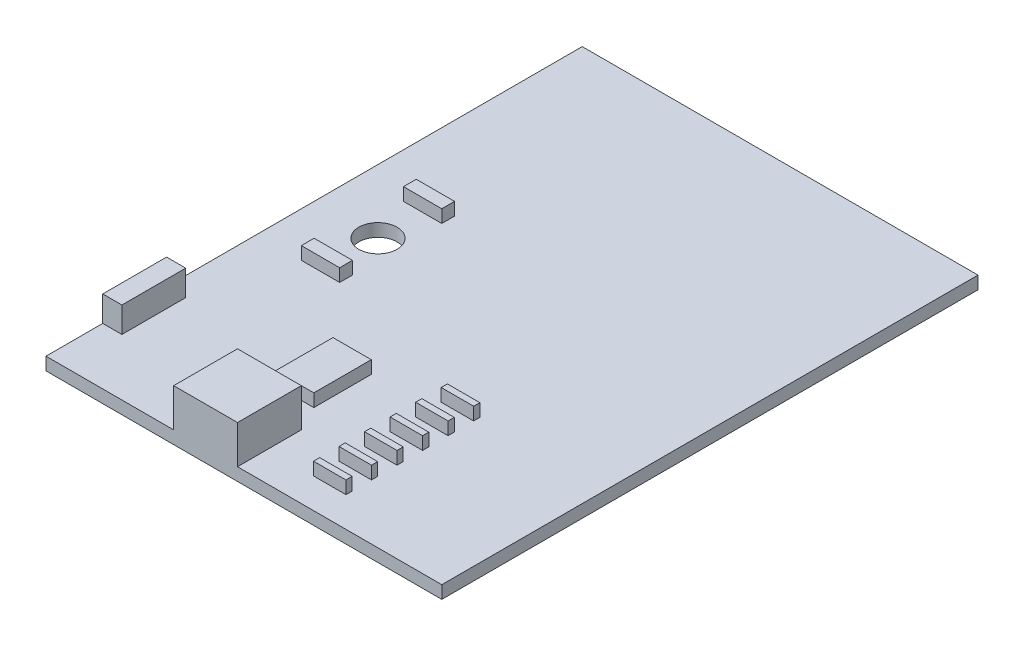
from build123d import *

# Parameters (mm, degrees)
SKETCH_1_W      = 31
SKETCH_1_H      = 42
SKETCH_1_R      = 1.5
EXTRUDE_1_DEPTH = 1
SKETCH_2_W      = 5
SKETCH_2_H      = 5
EXTRUDE_2_DEPTH = 3
SKETCH_3_W      = 3
SKETCH_3_H      = 4.5
SKETCH_3_W_2    = 2.541472094
SKETCH_3_H_2    = 0.485869665
EXTRUDE_3_DEPTH = 1
SKETCH_4_W      = 3
SKETCH_4_H      = 1
EXTRUDE_4_DEPTH = 1
SKETCH_5_W      = 1.5
SKETCH_5_H      = 5
EXTRUDE_5_DEPTH = 2


with BuildPart() as part:
    # 草圖1 → 填料-伸長1 (new body)
    with BuildSketch(Plane(origin=(0, 0, 0), x_dir=(1, 0, 0), z_dir=(0, 1, 0))):
        with Locations((15.5, 21)):
            Rectangle(SKETCH_1_W, SKETCH_1_H)
        with Locations((5, 21)):
            Circle(SKETCH_1_R, mode=Mode.SUBTRACT)
    extrude(amount=EXTRUDE_1_DEPTH)

    # 草圖2 → 填料-伸長2 (add)
    with BuildSketch(Plane(origin=(0, 1, 0), x_dir=(1, 0, 0), z_dir=(0, 1, 0))):
        with Locations((12.5, 2.5)):
            Rectangle(SKETCH_2_W, SKETCH_2_H)
    extrude(amount=EXTRUDE_2_DEPTH)

    # 草圖3 → 填料-伸長3 (add)
    with BuildSketch(Plane(origin=(0, 1, 0), x_dir=(1, 0, 0), z_dir=(0, 1, 0))):
        with Locations((12.476364023, 9.25)):
            Rectangle(SKETCH_3_W, SKETCH_3_H)
        with Locations((19.871516351, 12.595108575)):
            Rectangle(SKETCH_3_W_2, SKETCH_3_H_2)
        with Locations((19.871516351, 10.595108575)):
            Rectangle(SKETCH_3_W_2, SKETCH_3_H_2)
        with Locations((19.871516351, 8.595108574)):
            Rectangle(SKETCH_3_W_2, SKETCH_3_H_2)
        with Locations((19.871516351, 6.595108575)):
            Rectangle(SKETCH_3_W_2, SKETCH_3_H_2)
        with Locations((19.871516351, 4.595108575)):
            Rectangle(SKETCH_3_W_2, SKETCH_3_H_2)
        with Locations((19.871516351, 2.595108575)):
            Rectangle(SKETCH_3_W_2, SKETCH_3_H_2)
    extrude(amount=EXTRUDE_3_DEPTH)

    # 草圖4 → 填料-伸長4 (add)
    with BuildSketch(Plane(origin=(0, 1, 0), x_dir=(1, 0, 0), z_dir=(0, 1, 0))):
        with Locations((5, 25)):
            Rectangle(SKETCH_4_W, SKETCH_4_H)
        with Locations((5, 17)):
            Rectangle(SKETCH_4_W, SKETCH_4_H)
    extrude(amount=EXTRUDE_4_DEPTH)

    # 草圖5 → 填料-伸長5 (add)
    with BuildSketch(Plane(origin=(0, 1, 0), x_dir=(1, 0, 0), z_dir=(0, 1, 0))):
        with Locations((0.75, 6.944626386)):
            Rectangle(SKETCH_5_W, SKETCH_5_H)
    extrude(amount=EXTRUDE_5_DEPTH)


solid = part.part
